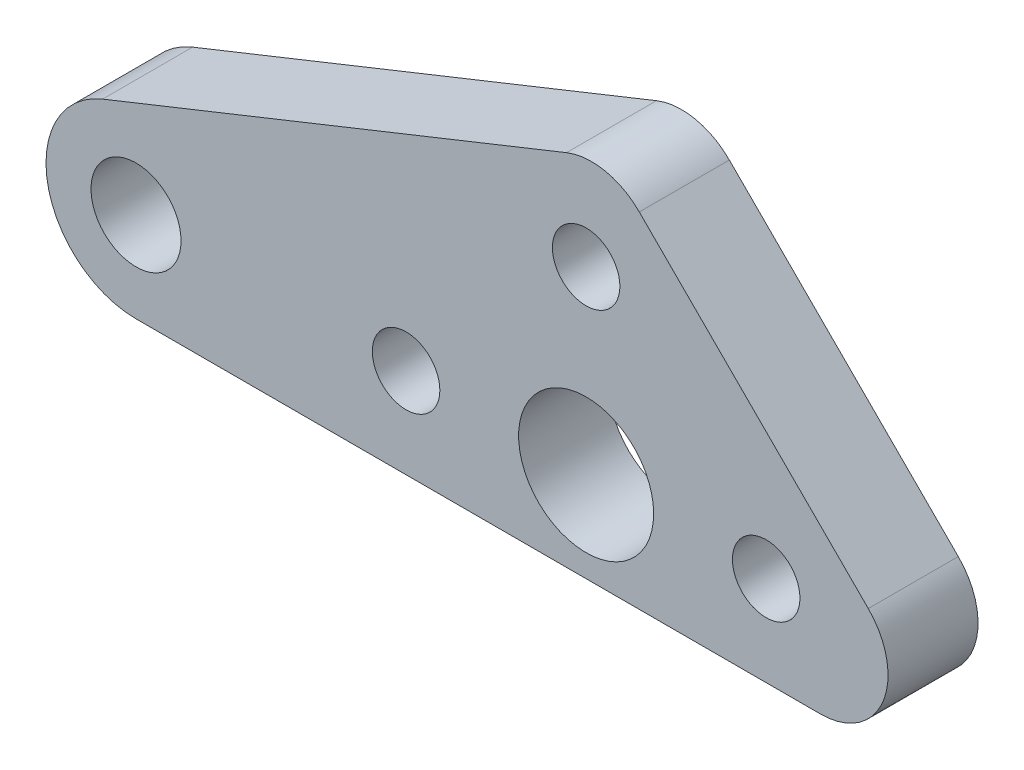
from build123d import *

# Parameters (mm, degrees)
SKETCH_1_R      = 1.5
SKETCH_1_R_2    = 2
SKETCH_1_R_3    = 3
EXTRUDE_1_DEPTH = 4


with BuildPart() as part:
    # 草图1 → 凸台-拉伸1 (new body)
    with BuildSketch(Plane.XY):
        with BuildLine():
            Line((-0.873328743, 11.958800349), (-21.485562705, 3.713906764))
            ThreePointArc((-21.485562705, 3.713906764), (-23.927825547, -0.756430085), (-20, -4))
            Line((-20, -4), (10.414213562, -4))
            ThreePointArc((10.414213562, -4), (13.18585216, -2.148050297), (12.535533906, 1.121320344))
            Line((12.535533906, 1.121320344), (2.36216363, 11.29469062))
            ThreePointArc((2.36216363, 11.29469062), (0.844040903, 12.112103444), (-0.873328743, 11.958800349))
        make_face()
        with Locations((0, 8)):
            Circle(SKETCH_1_R, mode=Mode.SUBTRACT)
        with Locations((8, 0)):
            Circle(SKETCH_1_R, mode=Mode.SUBTRACT)
        with Locations((-20, 0)):
            Circle(SKETCH_1_R_2, mode=Mode.SUBTRACT)
        Circle(SKETCH_1_R_3, mode=Mode.SUBTRACT)
        with Locations((-8, 0)):
            Circle(SKETCH_1_R, mode=Mode.SUBTRACT)
    extrude(amount=EXTRUDE_1_DEPTH)


solid = part.part
